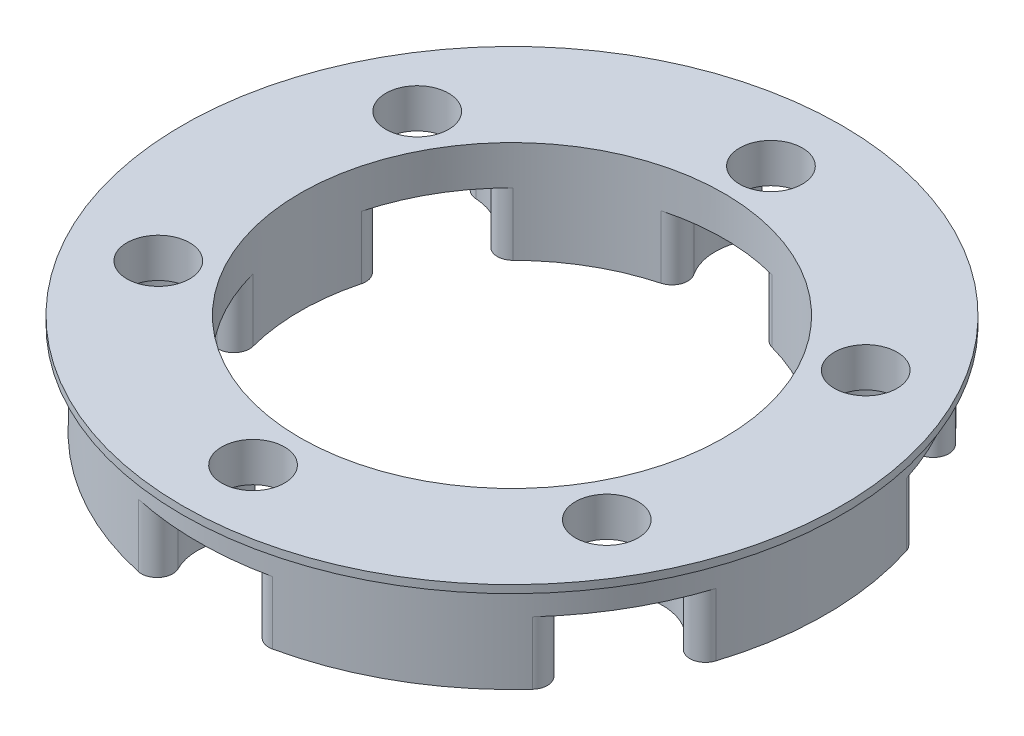
from build123d import *

# Parameters (mm, degrees)
SKETCH1_R                = 20
SKETCH1_R_2              = 13.5
BOSS_EXTRUDE1_DEPTH      = 6
SKETCH2_R                = 2
CUT_EXTRUDE1_DEPTH       = 29.91366459
SKETCH3_R                = 3.55
CUT_EXTRUDE4_DEPTH       = 4
FILLET1_R                = 1
CIRPATTERN2_COUNT        = 6
FILLET1_OF_CIRPATTERN2_R = 1
SKETCH4_R                = 21
SKETCH4_R_2              = 2
SKETCH4_R_3              = 13.5
BOSS_EXTRUDE3_DEPTH      = 0.5


with BuildPart() as part:
    # Sketch1 → Boss-Extrude1 (new body)
    with BuildSketch(Plane(origin=(0, 0, 0), x_dir=(1, 0, 0), z_dir=(0, 1, 0))):
        with Locations(Location((0, 0, 0), (0, 0, 270))):
            Circle(SKETCH1_R)
        with Locations(Location((0, 0, 0), (0, 0, 270))):
            Circle(SKETCH1_R_2, mode=Mode.SUBTRACT)
    extrude(amount=BOSS_EXTRUDE1_DEPTH)

    # Sketch2 → Cut-Extrude1 (cut, through all)
    with BuildSketch(Plane(origin=(0, 6, 0), x_dir=(1, 0, 0), z_dir=(0, 1, 0))):
        with Locations(Location((0, 16.5, 0), (0, 0, 270))):
            Circle(SKETCH2_R)
    cut_extrude1 = extrude(amount=-CUT_EXTRUDE1_DEPTH, mode=Mode.SUBTRACT)

    # Sketch3 → Cut-Extrude4 (cut)
    with BuildSketch(Plane(origin=(0, 0, 0), x_dir=(1, 0, 0), z_dir=(0, 1, 0))):
        with Locations((0, 16.5)):
            Circle(SKETCH3_R)
    cut_extrude4 = extrude(amount=CUT_EXTRUDE4_DEPTH, mode=Mode.SUBTRACT)

    # Fillet1
    fillet1_edges = [part.edges().sort_by_distance(p)[0] for p in [
        (-1.713354207, 2, -13.390833333),
        (1.713354207, 2, -13.390833333),
        (0.653573734, 2, -19.989318182),
        (-0.653573734, 2, -19.989318182),
    ]]
    fillet(fillet1_edges, radius=FILLET1_R)

    # CirPattern2: Cut-Extrude1, Cut-Extrude4 ×6 about axis
    cirpattern2_axis = Axis((0, 0, 0), (0, 1, 0))
    add([cut_extrude1.rotate(cirpattern2_axis, i * 360 / CIRPATTERN2_COUNT) for i in range(1, CIRPATTERN2_COUNT)], mode=Mode.SUBTRACT)
    add([cut_extrude4.rotate(cirpattern2_axis, i * 360 / CIRPATTERN2_COUNT) for i in range(1, CIRPATTERN2_COUNT)], mode=Mode.SUBTRACT)

    # Fillet1 of CirPattern2
    fillet1_of_cirpattern2_edges = [part.edges().sort_by_distance(p)[0] for p in [
        (-12.453478948, 2, -5.211608398),
        (-10.740124741, 2, -8.179224936),
        (-16.984470483, 2, -10.560670548),
        (-17.638044217, 2, -9.428647634),
        (-10.740124741, 2, 8.179224936),
        (-12.453478948, 2, 5.211608398),
        (-17.638044217, 2, 9.428647634),
        (-16.984470483, 2, 10.560670548),
        (1.713354207, 2, 13.390833333),
        (-1.713354207, 2, 13.390833333),
        (-0.653573734, 2, 19.989318182),
        (0.653573734, 2, 19.989318182),
        (12.453478948, 2, 5.211608398),
        (10.740124741, 2, 8.179224936),
        (16.984470483, 2, 10.560670548),
        (17.638044217, 2, 9.428647634),
        (10.740124741, 2, -8.179224936),
        (12.453478948, 2, -5.211608398),
        (17.638044217, 2, -9.428647634),
        (16.984470483, 2, -10.560670548),
    ]]
    fillet(fillet1_of_cirpattern2_edges, radius=FILLET1_OF_CIRPATTERN2_R)

    # Sketch4 → Boss-Extrude3 (add)
    with BuildSketch(Plane(origin=(0, 6, 0), x_dir=(1, 0, 0), z_dir=(0, 1, 0))):
        with Locations(Location((0, 0, 0), (0, 0, 270))):
            Circle(SKETCH4_R)
        with Locations(Location((14.289419162, 8.25, 0), (0, 0, 270))):
            Circle(SKETCH4_R_2, mode=Mode.SUBTRACT)
        with Locations(Location((14.289419162, -8.25, 0), (0, 0, 270))):
            Circle(SKETCH4_R_2, mode=Mode.SUBTRACT)
        with Locations(Location((0, -16.5, 0), (0, 0, 270))):
            Circle(SKETCH4_R_2, mode=Mode.SUBTRACT)
        with Locations(Location((0, 0, 0), (0, 0, 74.816955984))):
            Circle(SKETCH4_R_3, mode=Mode.SUBTRACT)
        with Locations(Location((-14.289419162, -8.25, 0), (0, 0, 270))):
            Circle(SKETCH4_R_2, mode=Mode.SUBTRACT)
        with Locations(Location((-14.289419162, 8.25, 0), (0, 0, 270))):
            Circle(SKETCH4_R_2, mode=Mode.SUBTRACT)
        with Locations(Location((0, 16.5, 0), (0, 0, 270))):
            Circle(SKETCH4_R_2, mode=Mode.SUBTRACT)
    extrude(amount=BOSS_EXTRUDE3_DEPTH)


solid = part.part
